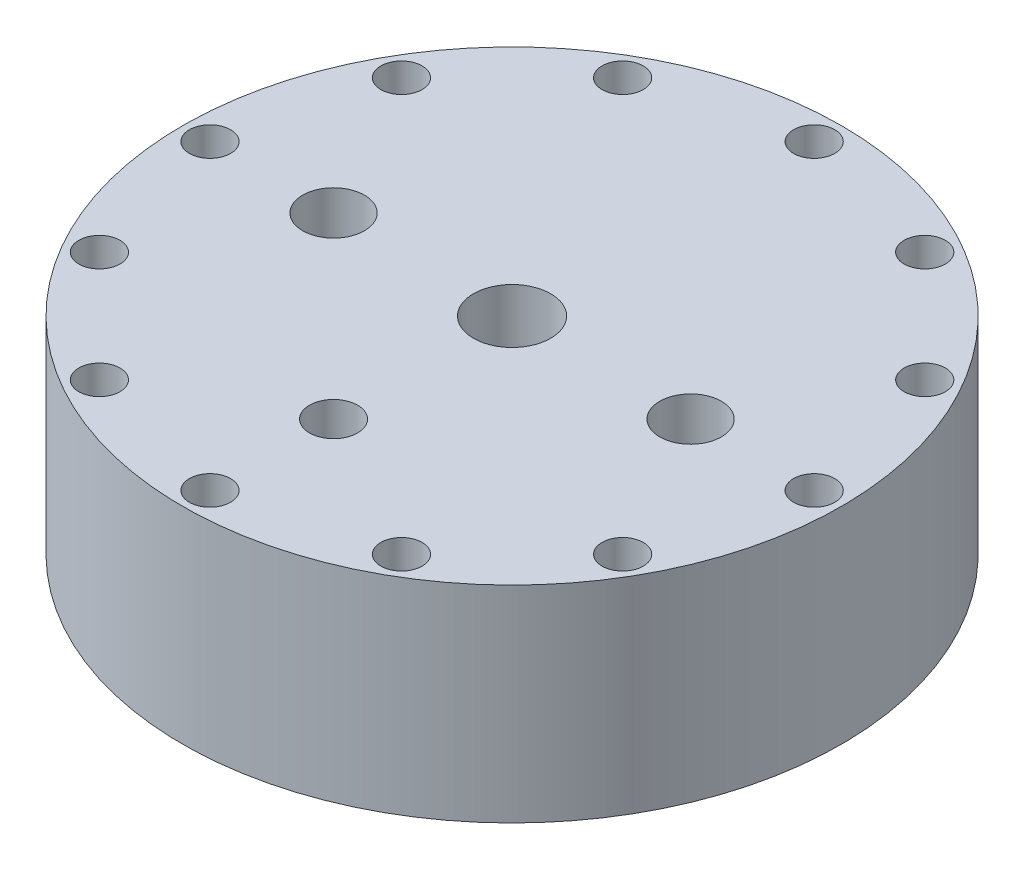
from build123d import *

# Parameters (mm, degrees)
CIRPATTERN1_COUNT                 = 12
PIPE_TAP_DRILL_FOR_1_2_TAP1_D     = 17.8562
PIPE_TAP_DRILL_FOR_1_2_TAP1_DEPTH = 19.05
PIPE_TAP_DRILL_FOR_1_2_TAP1_TIP   = 5.364543693
CIRPATTERN2_COUNT                 = 2
PIPE_TAP_DRILL_FOR_1_4_TAP1_D     = 11.1252
PIPE_TAP_DRILL_FOR_1_4_TAP1_DEPTH = 31.75
PIPE_TAP_DRILL_FOR_1_4_TAP1_TIP   = 3.342347279


with BuildPart() as part:
    # Sketch1 → Revolve1 (revolve)
    with BuildSketch(Plane.XY):
        Polygon((0, 0), (-76.2, 0), (-76.2, -47.6377), (-63.6524, -47.6377), (-63.6524, -44.9453), (-59.5884, -44.9453), (-59.5884, -47.6377), (-57.15, -47.6377), (-57.15, -41.2877), (-50.8, -41.2877), (-50.8, -28.5877), (-25.4, -28.5877), (-25.4, -22.2377), (-12.7, -15.8877), (0, -15.8877), align=None)
    revolve(axis=Axis((0, -15.8877, 0), (0, 1, 0)))

    # Sketch3 → 3/8 (0.375) Diameter Hole1 (revolve, cut)
    with BuildSketch(Plane(origin=(-69.85, 0, 0), x_dir=(0, 0, 1), z_dir=(1, 0, 0))):
        Polygon((0, 0), (0, 60.011598698), (4.7625, 57.15), (4.7625, 0), align=None)
    f_3_8_0_375_diameter_hole1 = revolve(axis=Axis((-69.85, 6.35, 0), (0, -1, 0)), mode=Mode.SUBTRACT)

    # CirPattern1: 3/8 (0.375) Diameter Hole1 ×12 about axis
    cirpattern1_axis = Axis((0, 0, 0), (0, 1, 0))
    for i in range(1, CIRPATTERN1_COUNT):
        add(f_3_8_0_375_diameter_hole1.rotate(cirpattern1_axis, i * 360 / CIRPATTERN1_COUNT), mode=Mode.SUBTRACT)

    # Pipe Tap Drill for 1/2 Tap1
    with Locations(Plane(origin=(0, 0, 0), x_dir=(1, 0, 0), z_dir=(0, 1, 0))):
        with Locations((0, 0)):
            Hole(PIPE_TAP_DRILL_FOR_1_2_TAP1_D / 2, depth=PIPE_TAP_DRILL_FOR_1_2_TAP1_DEPTH)
            with Locations((0, 0, -(PIPE_TAP_DRILL_FOR_1_2_TAP1_DEPTH + PIPE_TAP_DRILL_FOR_1_2_TAP1_TIP / 2))):  # 118° drill point
                Cone(0, PIPE_TAP_DRILL_FOR_1_2_TAP1_D / 2, PIPE_TAP_DRILL_FOR_1_2_TAP1_TIP, mode=Mode.SUBTRACT)

    # Sketch7 → Pipe Tap Drill for 3/8 Tap1 (revolve, cut)
    with BuildSketch(Plane(origin=(-41.275, 0, 0), x_dir=(0, 0, 1), z_dir=(1, 0, 0))):
        Polygon((0, 0), (0, 36.038582582), (7.1374, 31.75), (7.1374, 0), align=None)
    pipe_tap_drill_for_3_8_tap1 = revolve(axis=Axis((-41.275, 6.35, 0), (0, -1, 0)), mode=Mode.SUBTRACT)

    # CirPattern2: Pipe Tap Drill for 3/8 Tap1 ×2 about axis
    cirpattern2_axis = Axis((0, 0, 0), (0, 1, 0))
    for i in range(1, CIRPATTERN2_COUNT):
        add(pipe_tap_drill_for_3_8_tap1.rotate(cirpattern2_axis, i * 360 / CIRPATTERN2_COUNT), mode=Mode.SUBTRACT)

    # Pipe Tap Drill for 1/4 Tap1
    with Locations(Plane(origin=(0, 0, 0), x_dir=(1, 0, 0), z_dir=(0, 1, 0))):
        with Locations((0, -41.275)):
            Hole(PIPE_TAP_DRILL_FOR_1_4_TAP1_D / 2, depth=PIPE_TAP_DRILL_FOR_1_4_TAP1_DEPTH)
            with Locations((0, 0, -(PIPE_TAP_DRILL_FOR_1_4_TAP1_DEPTH + PIPE_TAP_DRILL_FOR_1_4_TAP1_TIP / 2))):  # 118° drill point
                Cone(0, PIPE_TAP_DRILL_FOR_1_4_TAP1_D / 2, PIPE_TAP_DRILL_FOR_1_4_TAP1_TIP, mode=Mode.SUBTRACT)


solid = part.part
